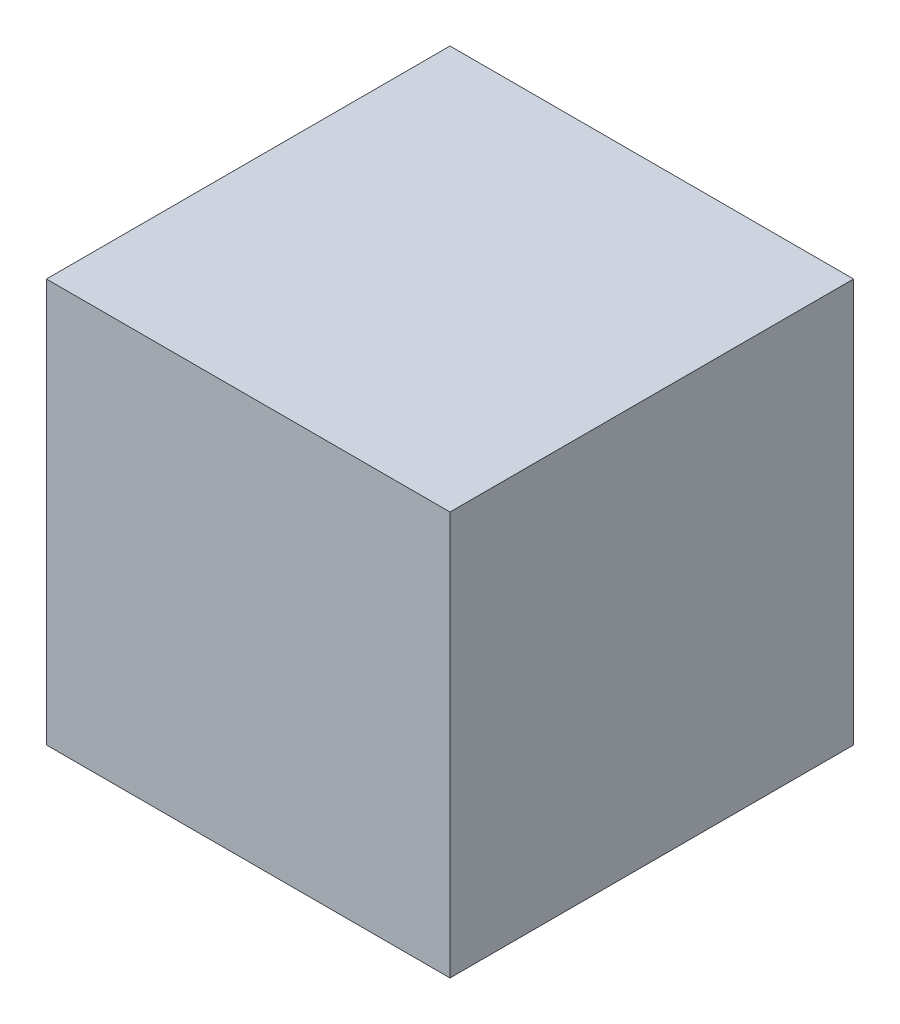
from build123d import *

# Parameters (mm, degrees)
SKETCH_1_W      = 10
SKETCH_1_H      = 10
EXTRUDE_1_DEPTH = 5


with BuildPart() as part:
    # Эскиз1 → Бобышка-Вытянуть1 (new body, symmetric)
    with BuildSketch(Plane(origin=(0, 0, 0), x_dir=(1, 0, 0), z_dir=(0, 1, 0))):
        Rectangle(SKETCH_1_W, SKETCH_1_H)
    extrude(amount=EXTRUDE_1_DEPTH, both=True)


solid = part.part
